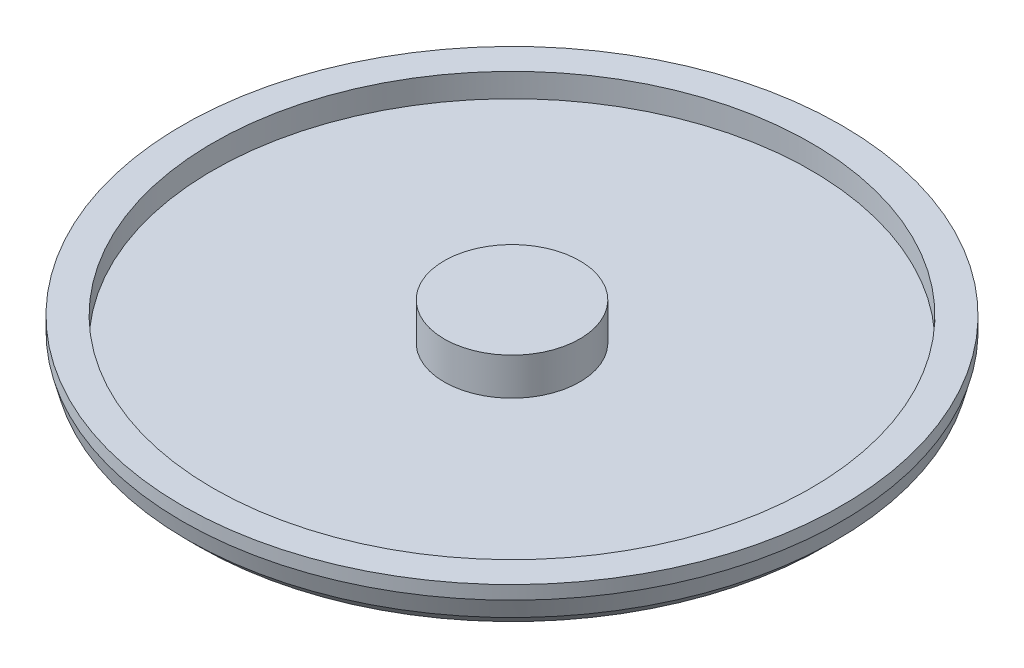
from build123d import *

# Parameters (mm, degrees)
SKETCH1_R           = 486.25
BOSS_EXTRUDE1_DEPTH = 65
SKETCH3_R           = 441.25
CUT_EXTRUDE1_DEPTH  = 35
SKETCH6_R           = 100
BOSS_EXTRUDE3_DEPTH = 55


with BuildPart() as part:
    # Sketch1 → Boss-Extrude1 (new body)
    with BuildSketch(Plane(origin=(0, 0, 0), x_dir=(1, 0, 0), z_dir=(0, 1, 0))):
        Circle(SKETCH1_R)
    extrude(amount=BOSS_EXTRUDE1_DEPTH)

    # Sketch3 → Cut-Extrude1 (cut)
    with BuildSketch(Plane(origin=(0, 65, 0), x_dir=(1, 0, 0), z_dir=(0, 1, 0))):
        Circle(SKETCH3_R)
    extrude(amount=-CUT_EXTRUDE1_DEPTH, mode=Mode.SUBTRACT)

    # Sketch5 → Cut-Revolve1 (revolve, cut)
    with BuildSketch(Plane(origin=(0, 0, 0), x_dir=(0, 0, -1), z_dir=(1, 0, 0))):
        Polygon((486.25, 45), (478.929491924, 17.679491924), (461.25, 0), (486.25, 0), align=None)
    revolve(axis=Axis((0, 89.25, 0), (0, -1, 0)), mode=Mode.SUBTRACT)

    # Sketch6 → Boss-Extrude3 (add)
    with BuildSketch(Plane(origin=(0, 30, 0), x_dir=(1, 0, 0), z_dir=(0, 1, 0))):
        Circle(SKETCH6_R)
    extrude(amount=BOSS_EXTRUDE3_DEPTH)


solid = part.part
